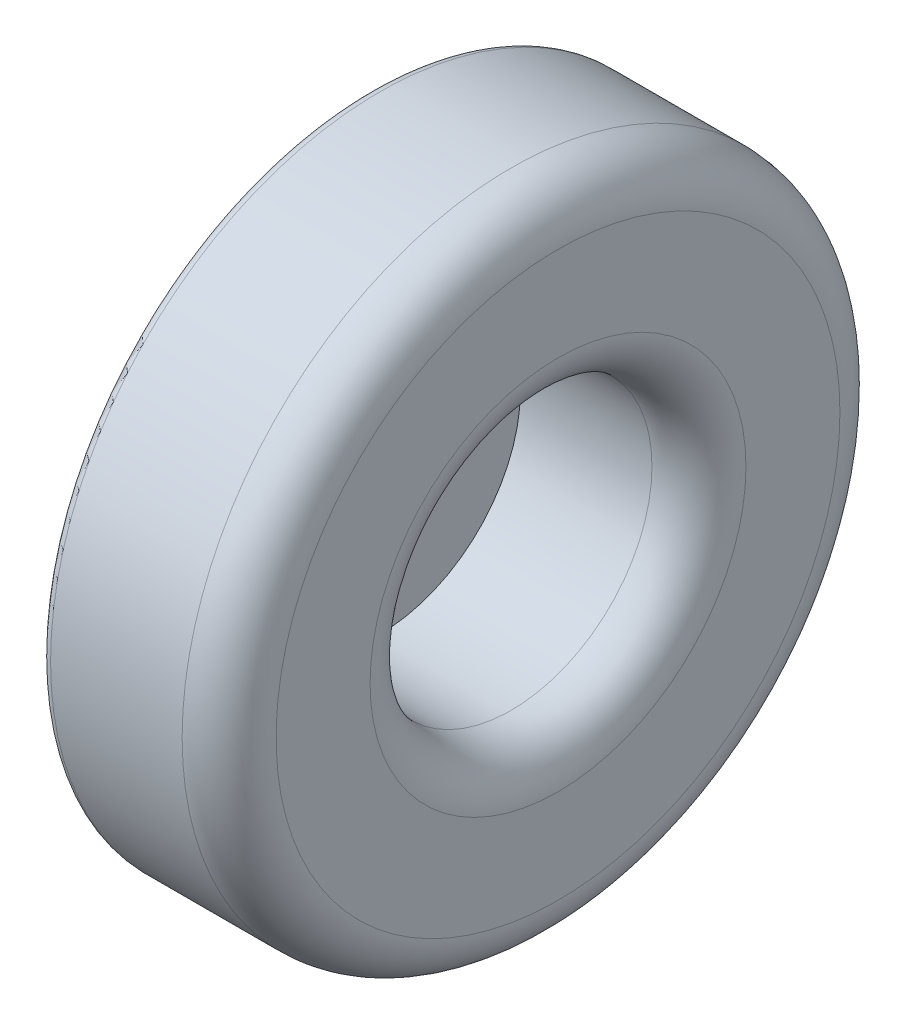
from build123d import *

# Parameters (mm, degrees)
SKETCH1_R           = 35
BOSS_EXTRUDE1_DEPTH = 20
SKETCH2_R           = 15
CUT_EXTRUDE1_DEPTH  = 19
FILLET1_R           = 5
FILLET2_R           = 1


with BuildPart() as part:
    # Sketch1 → Boss-Extrude1 (new body)
    with BuildSketch(Plane(origin=(0, 0, 0), x_dir=(0, 0, -1), z_dir=(1, 0, 0))):
        Circle(SKETCH1_R)
    extrude(amount=BOSS_EXTRUDE1_DEPTH)

    # Sketch2 → Cut-Extrude1 (cut)
    with BuildSketch(Plane(origin=(20, 0, 0), x_dir=(0, 0, -1), z_dir=(1, 0, 0))):
        Circle(SKETCH2_R)
    extrude(amount=-CUT_EXTRUDE1_DEPTH, mode=Mode.SUBTRACT)

    # Fillet1
    fillet1_edges = [part.edges().sort_by_distance(p)[0] for p in [
        (20, 0, 35),
        (20, 0, 15),
    ]]
    fillet(fillet1_edges, radius=FILLET1_R)

    # Fillet2
    fillet2_edges = [part.edges().sort_by_distance(p)[0] for p in [
        (0, 0, 35),
    ]]
    fillet(fillet2_edges, radius=FILLET2_R)


solid = part.part
